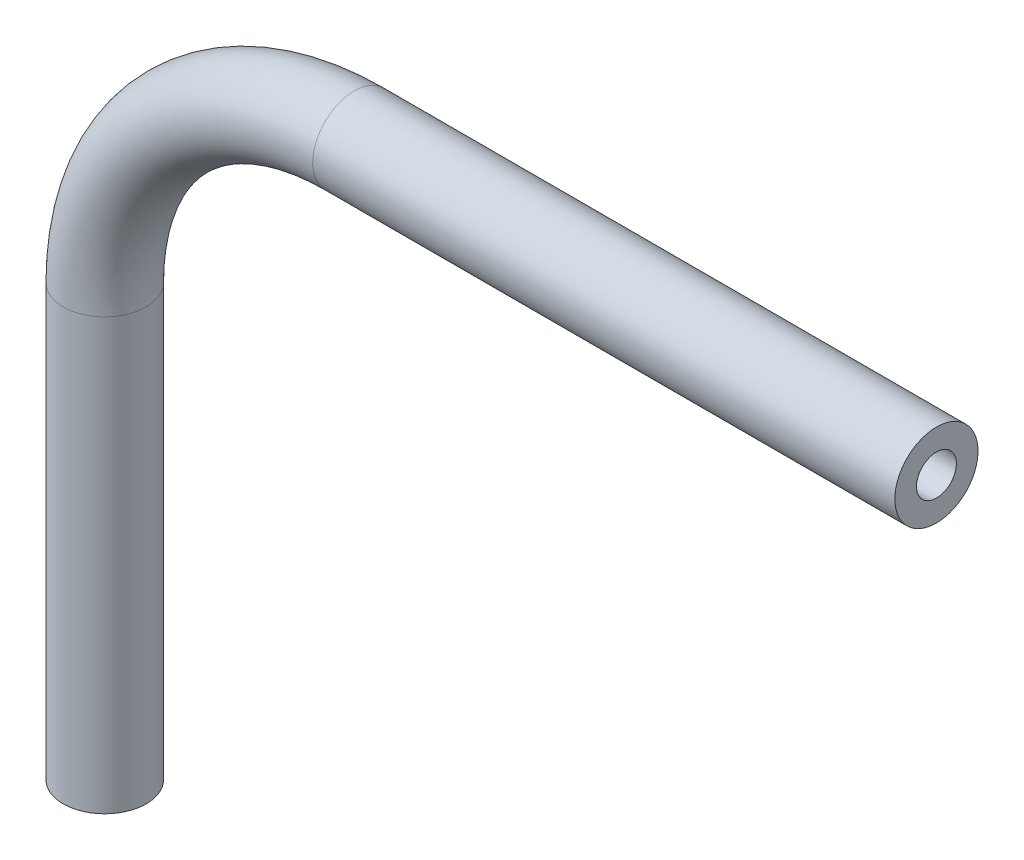
from build123d import *

# Parameters (mm, degrees)
SKETCH2_R   = 3.175
SKETCH2_R_2 = 1.524


with BuildPart() as part:
    # Sweep1: sweep along a path in Sketch1
    with BuildLine(Plane.XY) as sweep1_path:
        Line((0, -34.380773881), (0, -1.522317881))
        ThreePointArc((0, -1.522317881), (5.579615818, 11.948066301), (19.05, 17.527682119))
        Line((19.05, 17.527682119), (63.5, 17.527682119))
    # Sketch2 → Sweep1 (sweep)
    with BuildSketch(Plane(origin=(63.5, 17.527682119, 0), x_dir=(0, 0, -1), z_dir=(1, 0, 0))):
        Circle(SKETCH2_R)
        Circle(SKETCH2_R_2, mode=Mode.SUBTRACT)
    sweep(path=sweep1_path.line)


solid = part.part
